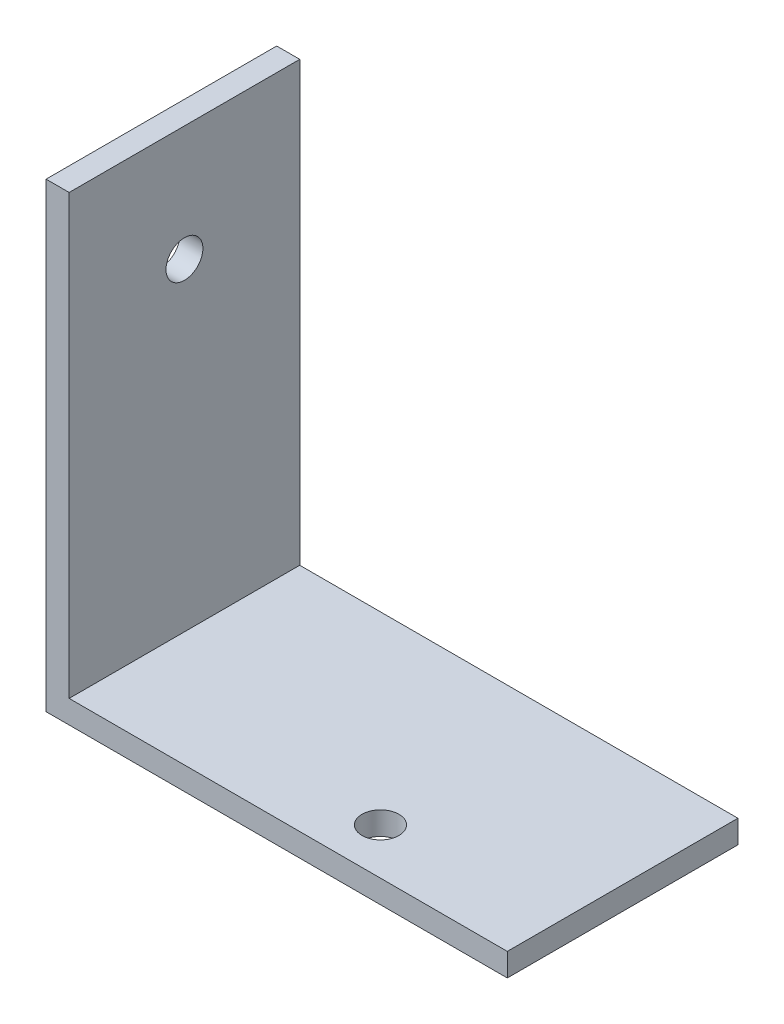
from build123d import *

# Parameters (mm, degrees)
EXTRUDE_1_DEPTH     = 20
SKETCH_3_R          = 1.6
CUT_EXTRUDE_2_DEPTH = 41
SKETCH_4_R          = 1.6
CUT_EXTRUDE_3_DEPTH = 41


with BuildPart() as part:
    # Эскиз1 → Бобышка-Вытянуть1 (new body)
    with BuildSketch(Plane.XY):
        Polygon((0, 0), (40, 0), (40, 2), (2, 2), (2, 40), (0, 40), align=None)
    extrude(amount=EXTRUDE_1_DEPTH)

    # Эскиз3 → Вырез-Вытянуть2 (cut, through all)
    with BuildSketch(Plane.ZY):
        with Locations((10, 30)):
            Circle(SKETCH_3_R)
    extrude(amount=-CUT_EXTRUDE_2_DEPTH, mode=Mode.SUBTRACT)

    # Эскиз4 → Вырез-Вытянуть3 (cut, through all)
    with BuildSketch(Plane.XZ):
        with Locations((25, 16)):
            Circle(SKETCH_4_R)
    extrude(amount=-CUT_EXTRUDE_3_DEPTH, mode=Mode.SUBTRACT)


solid = part.part
